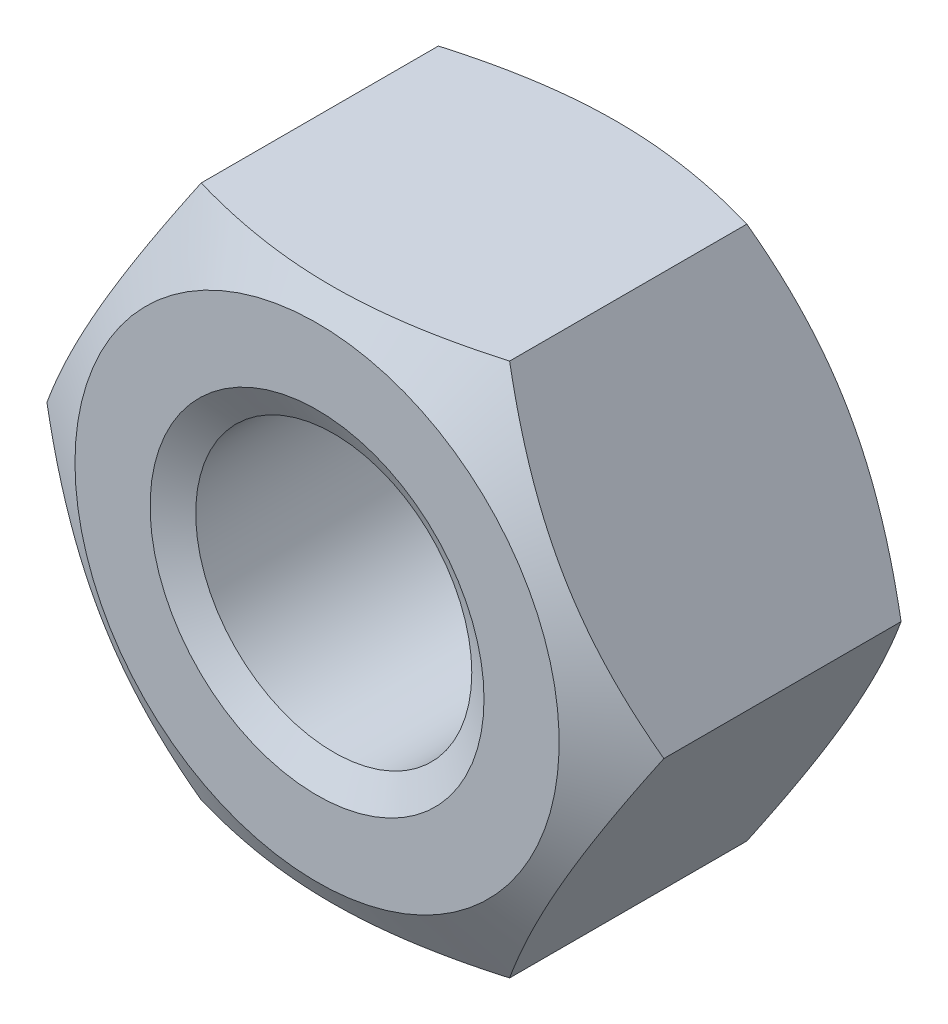
from build123d import *

# Parameters (mm, degrees)
SKETCH1_R               = 2.067
BASENUT_DEPTH           = 4.7
ENDCHAMFER_SIZE         = 0.433
ENDCHAMFER_SIZE2        = 0.249992667
ENDCHAMFER_PART_2_SIZE  = 0.433
ENDCHAMFER_PART_2_SIZE2 = 0.249992667


with BuildPart() as part:
    # Sketch1 → BaseNut (new body)
    with BuildSketch(Plane.XY):
        Polygon((4.618802154, 0), (2.309401077, 4), (-2.309401077, 4), (-4.618802154, 0), (-2.309401077, -4), (2.309401077, -4), align=None)
        Circle(SKETCH1_R, mode=Mode.SUBTRACT)
    extrude(amount=-BASENUT_DEPTH)

    # Sketch2 → Double-Chamfer (revolve, cut)
    with BuildSketch(Plane(origin=(0, 0, 0), x_dir=(1, 0, 0), z_dir=(0, 1, 0))):
        Polygon((-4.618802154, 4.7), (-3.625, 4.7), (-4.618802154, 4.126228059), align=None)
        Polygon((-4.618802154, 0.573771941), (-4.618802154, 0), (-3.625, 0), align=None)
    revolve(axis=Axis((0, 0, -3.375940562), (0, 0, 1)), mode=Mode.SUBTRACT)

    # EndChamfer
    endchamfer_edges = [part.edges().sort_by_distance(p)[0] for p in [
        (-2.067, 0, -4.7),
    ]]
    endchamfer_side = [part.faces().sort_by_distance(p)[0] for p in [
        (-2.067, 0, -2.35),
    ]]
    chamfer(endchamfer_edges, length=ENDCHAMFER_SIZE, length2=ENDCHAMFER_SIZE2, reference=endchamfer_side[0])

    # EndChamfer part 2
    endchamfer_part_2_edges = [part.edges().sort_by_distance(p)[0] for p in [
        (-2.067, 0, 0),
    ]]
    endchamfer_part_2_side = [part.faces().sort_by_distance(p)[0] for p in [
        (3.522469517, 0, 0),
    ]]
    chamfer(endchamfer_part_2_edges, length=ENDCHAMFER_PART_2_SIZE, length2=ENDCHAMFER_PART_2_SIZE2, reference=endchamfer_part_2_side[0])


solid = part.part
